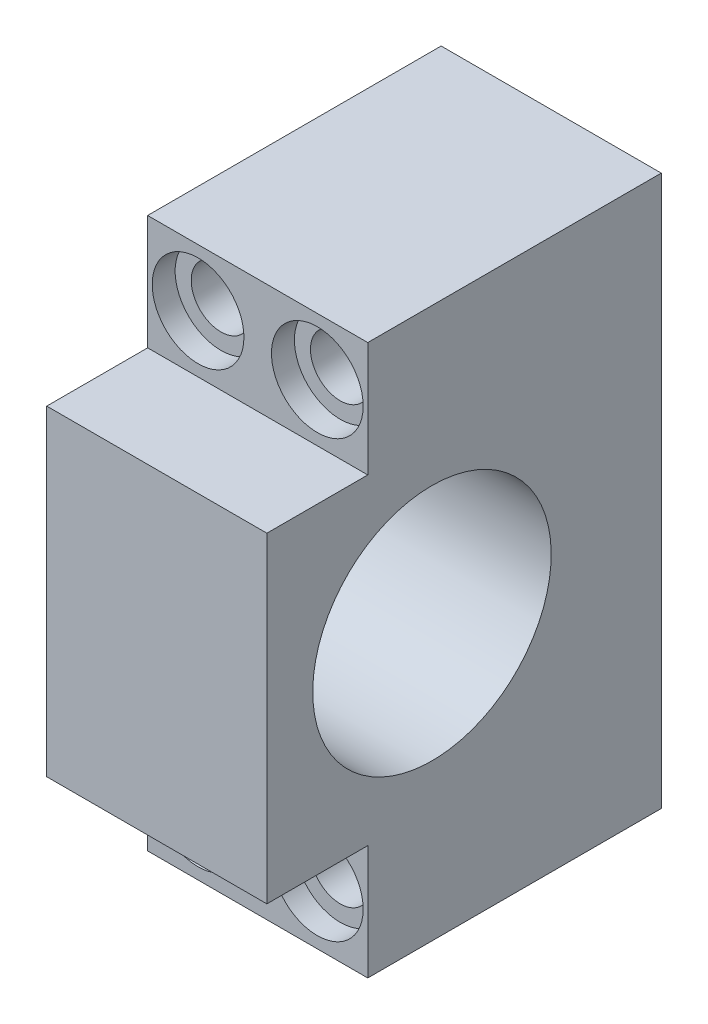
from build123d import *

# Parameters (mm, degrees)
SKETCH1_W           = 24
SKETCH1_H           = 60
BOSS_EXTRUDE1_DEPTH = 43
SKETCH2_W           = 24
SKETCH2_H           = 12.5
CUT_EXTRUDE1_DEPTH  = 11
SKETCH3_R           = 3.25
CUT_EXTRUDE2_DEPTH  = 33
SKETCH4_R           = 5
CUT_EXTRUDE3_DEPTH  = 2.5
SKETCH5_R           = 13
CUT_EXTRUDE4_DEPTH  = 25


with BuildPart() as part:
    # Sketch1 → Boss-Extrude1 (new body)
    with BuildSketch(Plane.XY):
        Rectangle(SKETCH1_W, SKETCH1_H)
    extrude(amount=BOSS_EXTRUDE1_DEPTH)

    # Sketch2 → Cut-Extrude1 (cut)
    with BuildSketch(Plane.XY.offset(43)):
        with Locations((0, -23.75)):
            Rectangle(SKETCH2_W, SKETCH2_H)
        with Locations((0, 23.75)):
            Rectangle(SKETCH2_W, SKETCH2_H)
    extrude(amount=-CUT_EXTRUDE1_DEPTH, mode=Mode.SUBTRACT)

    # Sketch3 → Cut-Extrude2 (cut, through all)
    with BuildSketch(Plane.XY.offset(32)):
        with Locations((-6.5, -23.75)):
            Circle(SKETCH3_R)
        with Locations((6.5, -23.75)):
            Circle(SKETCH3_R)
        with Locations((-6.5, 23.75)):
            Circle(SKETCH3_R)
        with Locations((6.5, 23.75)):
            Circle(SKETCH3_R)
    extrude(amount=-CUT_EXTRUDE2_DEPTH, mode=Mode.SUBTRACT)

    # Sketch4 → Cut-Extrude3 (cut)
    with BuildSketch(Plane.XY.offset(32)):
        with Locations((-6.5, 23.75)):
            Circle(SKETCH4_R)
        with Locations((6.5, 23.75)):
            Circle(SKETCH4_R)
        with Locations((-6.5, -23.75)):
            Circle(SKETCH4_R)
        with Locations((6.5, -23.75)):
            Circle(SKETCH4_R)
    extrude(amount=-CUT_EXTRUDE3_DEPTH, mode=Mode.SUBTRACT)

    # Sketch5 → Cut-Extrude4 (cut, through all)
    with BuildSketch(Plane(origin=(12, 0, 0), x_dir=(0, 0, -1), z_dir=(1, 0, 0))):
        with Locations((-25, 0)):
            Circle(SKETCH5_R)
    extrude(amount=-CUT_EXTRUDE4_DEPTH, mode=Mode.SUBTRACT)


solid = part.part
